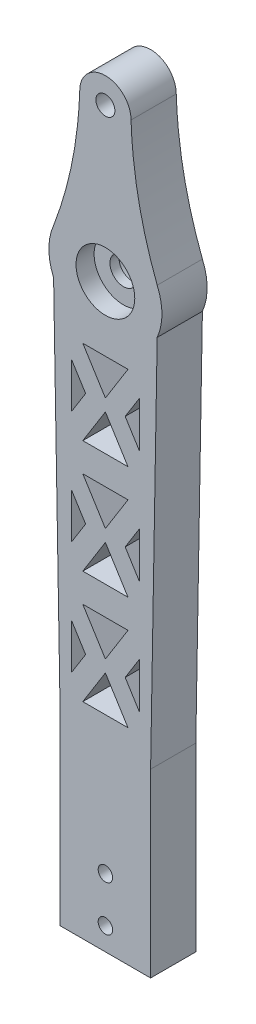
from build123d import *

# Parameters (mm, degrees)
BOSS_EXTRUDE1_DEPTH = 10
SKETCH2_R           = 2.1
SKETCH2_R_2         = 6.5
CUT_EXTRUDE1_DEPTH  = 4
SKETCH3_R           = 6.5
CUT_EXTRUDE2_DEPTH  = 4
SKETCH4_R           = 3
CUT_EXTRUDE3_DEPTH  = 7.0000001
SKETCH7_R           = 1.6
CUT_EXTRUDE6_DEPTH  = 11.0000001
SKETCH8_R           = 2.1
CUT_EXTRUDE7_DEPTH  = 11.0000001


with BuildPart() as part:
    # Sketch1 → Boss-Extrude1 (new body)
    with BuildSketch(Plane.XY):
        with BuildLine():
            Line((10, 0), (11.456439237, 83.439348028))
            ThreePointArc((11.456439237, 83.439348028), (12.5, 88.439348028), (11.456439237, 93.439348028))
            add(Edge.make_bspline(
                [(11.456439237, 93.439348028), (6.1563812, 107.325761573), (5.671965352, 122.191845585)],
                knots=[0, 0, 0, 1, 1, 1], degree=2))
            ThreePointArc((5.671965352, 122.191845585), (0, 127.863810938), (-5.671965352, 122.191845585))
            add(Edge.make_bspline(
                [(-11.456439237, 93.439348028), (-6.1563812, 107.325761573), (-5.671965352, 122.191845585)],
                knots=[0, 0, 0, 1, 1, 1], degree=2))
            ThreePointArc((-11.456439237, 93.439348028), (-12.5, 88.439348028), (-11.456439237, 83.439348028))
            Line((-11.456439237, 83.439348028), (-10, 0))
            Line((-10, 0), (-10, -40))
            Line((-10, -40), (10, -40))
            Line((10, -40), (10, 0))
        make_face()
        Polygon((-7.5, 19.769248097), (-4.375, 14.769248097), (-7.5, 9.769248097), align=None, mode=Mode.SUBTRACT)
        Polygon((-7.5, 44.769248097), (-4.375, 39.769248097), (-7.5, 34.769248097), align=None, mode=Mode.SUBTRACT)
        Polygon((-5, 5.439121078), (0, 13.439121078), (5, 5.439121078), align=None, mode=Mode.SUBTRACT)
        Polygon((0, 16.099375116), (-5, 24.099375116), (5, 24.099375116), align=None, mode=Mode.SUBTRACT)
        Polygon((7.5, 19.769248097), (7.5, 9.769248097), (4.375, 14.769248097), align=None, mode=Mode.SUBTRACT)
        Polygon((-5, 30.439121078), (0, 38.439121078), (5, 30.439121078), align=None, mode=Mode.SUBTRACT)
        Polygon((7.5, 44.769248097), (7.5, 34.769248097), (4.375, 39.769248097), align=None, mode=Mode.SUBTRACT)
        Polygon((-7.5, 69.769248097), (-4.375, 64.769248097), (-7.5, 59.769248097), align=None, mode=Mode.SUBTRACT)
        Polygon((5, 55.439121078), (-5, 55.439121078), (0, 63.439121078), align=None, mode=Mode.SUBTRACT)
        Polygon((0, 66.099375116), (-5, 74.099375116), (5, 74.099375116), align=None, mode=Mode.SUBTRACT)
        Polygon((0, 41.099375116), (-5, 49.099375116), (5, 49.099375116), align=None, mode=Mode.SUBTRACT)
        Polygon((4.375, 64.769248097), (7.5, 69.769248097), (7.5, 59.769248097), align=None, mode=Mode.SUBTRACT)
    extrude(amount=BOSS_EXTRUDE1_DEPTH)

    # Sketch2 → Cut-Extrude1 (cut)
    with BuildSketch(Plane.XY.offset(10)):
        with Locations((0, 122.191845585)):
            Circle(SKETCH2_R)
        with Locations((0, 88.439348028)):
            Circle(SKETCH2_R_2)
    extrude(amount=-CUT_EXTRUDE1_DEPTH, mode=Mode.SUBTRACT)

    # Sketch3 → Cut-Extrude2 (cut)
    with BuildSketch(Plane(origin=(0, 0, 0), x_dir=(-1, 0, 0), z_dir=(0, 0, -1))):
        with Locations((0, 88.439348028)):
            Circle(SKETCH3_R)
    extrude(amount=-CUT_EXTRUDE2_DEPTH, mode=Mode.SUBTRACT)

    # Sketch4 → Cut-Extrude3 (cut, through all)
    with BuildSketch(Plane(origin=(0, 0, 4), x_dir=(-1, 0, 0), z_dir=(0, 0, -1))):
        with Locations((0, 88.439348028)):
            Circle(SKETCH4_R)
    extrude(amount=-CUT_EXTRUDE3_DEPTH, mode=Mode.SUBTRACT)

    # Sketch7 → Cut-Extrude6 (cut, through all)
    with BuildSketch(Plane.XY.offset(10)):
        with Locations((0, -25)):
            Circle(SKETCH7_R)
        with Locations((0, -35)):
            Circle(SKETCH7_R)
    extrude(amount=-CUT_EXTRUDE6_DEPTH, mode=Mode.SUBTRACT)

    # Sketch8 → Cut-Extrude7 (cut, through all)
    with BuildSketch(Plane.XY.offset(10)):
        with Locations((0, 122.191845585)):
            Circle(SKETCH8_R)
    extrude(amount=-CUT_EXTRUDE7_DEPTH, mode=Mode.SUBTRACT)


solid = part.part
